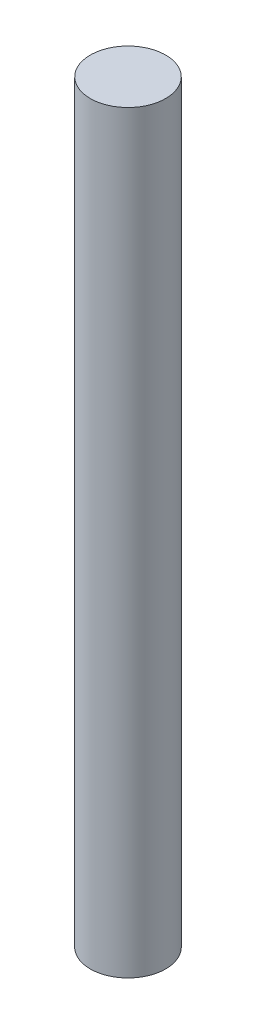
from build123d import *

# Parameters (mm, degrees)
SKETCH1_R           = 20
BOSS_EXTRUDE1_DEPTH = 400


with BuildPart() as part:
    # Sketch1 → Boss-Extrude1 (new body)
    with BuildSketch(Plane(origin=(0, 0, 0), x_dir=(1, 0, 0), z_dir=(0, 1, 0))):
        Circle(SKETCH1_R)
    extrude(amount=BOSS_EXTRUDE1_DEPTH)


solid = part.part
